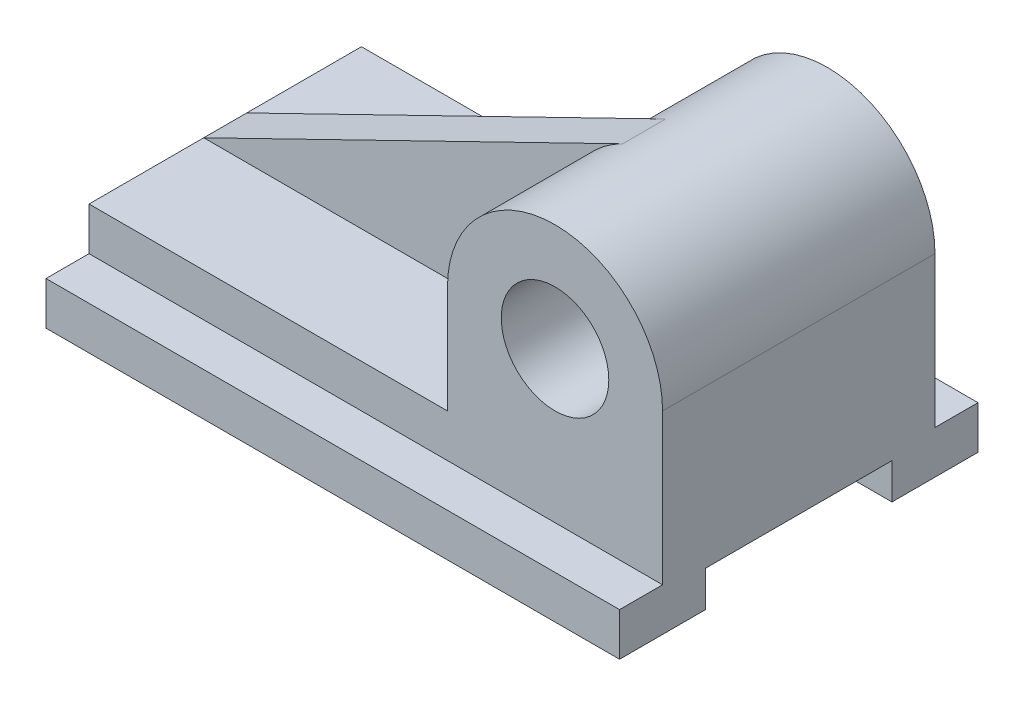
from build123d import *

# Parameters (mm, degrees)
SKETCH1_W           = 160
SKETCH1_H           = 24
BOSS_EXTRUDE1_DEPTH = 76
BOSS_EXTRUDE2_DEPTH = 12
SKETCH3_R           = 15
CUT_EXTRUDE1_DEPTH  = 95
CUT_EXTRUDE2_DEPTH  = 196
SKETCH5_W           = 160
SKETCH5_H           = 12
BOSS_EXTRUDE3_DEPTH = 12
SKETCH6_W           = 160
SKETCH6_H           = 12
BOSS_EXTRUDE4_DEPTH = 12


with BuildPart() as part:
    # Sketch1 → Boss-Extrude1 (new body)
    with BuildSketch(Plane.XY):
        Rectangle(SKETCH1_W, SKETCH1_H)
        with BuildLine():
            Line((20, 42), (20, 12))
            Line((20, 12), (80, 12))
            Line((80, 12), (80, 42))
            ThreePointArc((80, 42), (50, 72), (20, 42))
        make_face()
    extrude(amount=-BOSS_EXTRUDE1_DEPTH)

    # Sketch2 → Boss-Extrude2 (add)
    with BuildSketch(Plane.XY.offset(-32)):
        with BuildLine():
            Line((-80, 12), (36.853932584, 68.966292135))
            ThreePointArc((36.853932584, 68.966292135), (24.56005088, 57.8999682), (20, 42))
            Line((20, 42), (20, 12))
            Line((20, 12), (-80, 12))
        make_face()
    extrude(amount=-BOSS_EXTRUDE2_DEPTH)

    # Sketch3 → Cut-Extrude1 (cut)
    with BuildSketch(Plane.XY):
        with Locations((50, 42)):
            Circle(SKETCH3_R)
    extrude(amount=-CUT_EXTRUDE1_DEPTH, mode=Mode.SUBTRACT)

    # Sketch4 → Cut-Extrude2 (cut)
    with BuildSketch(Plane.ZY.offset(80)):
        Polygon((-38, -12), (-12, -12), (-12, -2), (-64, -2), (-64, -12), align=None)
    extrude(amount=-CUT_EXTRUDE2_DEPTH, mode=Mode.SUBTRACT)

    # Sketch5 → Boss-Extrude3 (add)
    with BuildSketch(Plane.XY):
        with Locations((0, -6)):
            Rectangle(SKETCH5_W, SKETCH5_H)
    extrude(amount=BOSS_EXTRUDE3_DEPTH)

    # Sketch6 → Boss-Extrude4 (add)
    with BuildSketch(Plane(origin=(0, 0, -76), x_dir=(-1, 0, 0), z_dir=(0, 0, -1))):
        with Locations((0, -6)):
            Rectangle(SKETCH6_W, SKETCH6_H)
    extrude(amount=BOSS_EXTRUDE4_DEPTH)


solid = part.part
